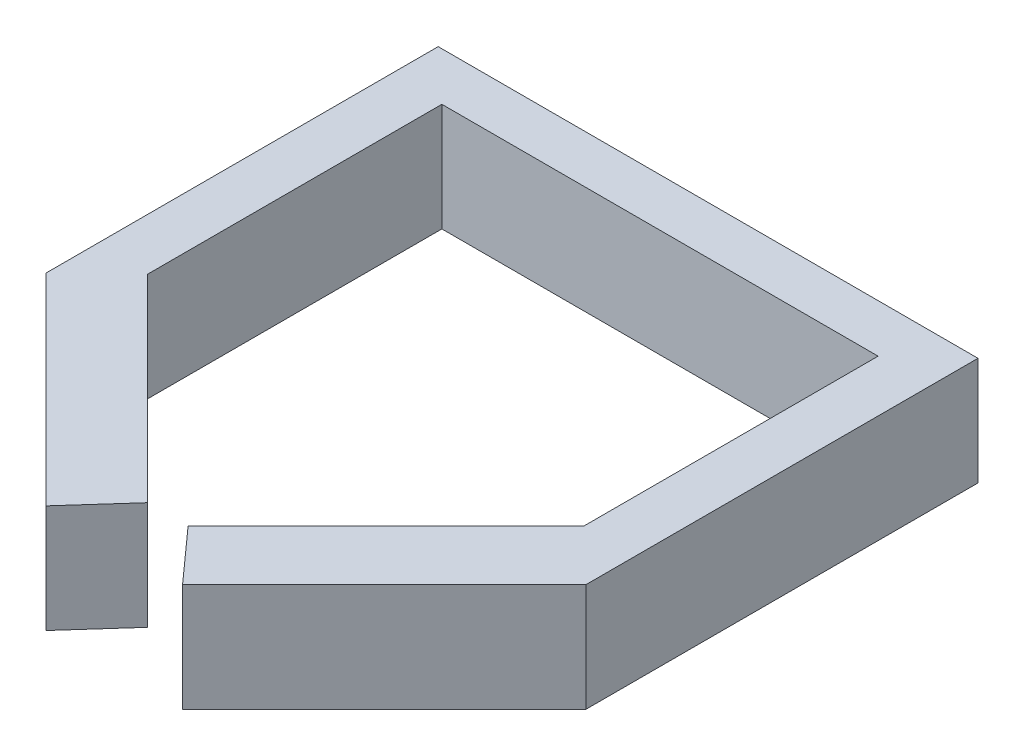
from build123d import *

# Parameters (mm, degrees)
BOSS_EXTRUDE1_DEPTH = 10


with BuildPart() as part:
    # Sketch1 → Boss-Extrude1 (new body)
    with BuildSketch(Plane(origin=(0, 0, 0), x_dir=(1, 0, 0), z_dir=(0, 1, 0))):
        Polygon((0, 18.676012461), (18.676012461, 0), (23.130841121, 4.968847352), (4.797507788, 23.302180685), (4.797507788, 50.54517134), (45.202492212, 50.54517134), (45.202492212, 23.302180685), (26.869158879, 4.968847352), (31.323987539, 0), (50, 18.676012461), (50, 55), (0, 55), align=None)
    extrude(amount=BOSS_EXTRUDE1_DEPTH)


solid = part.part
